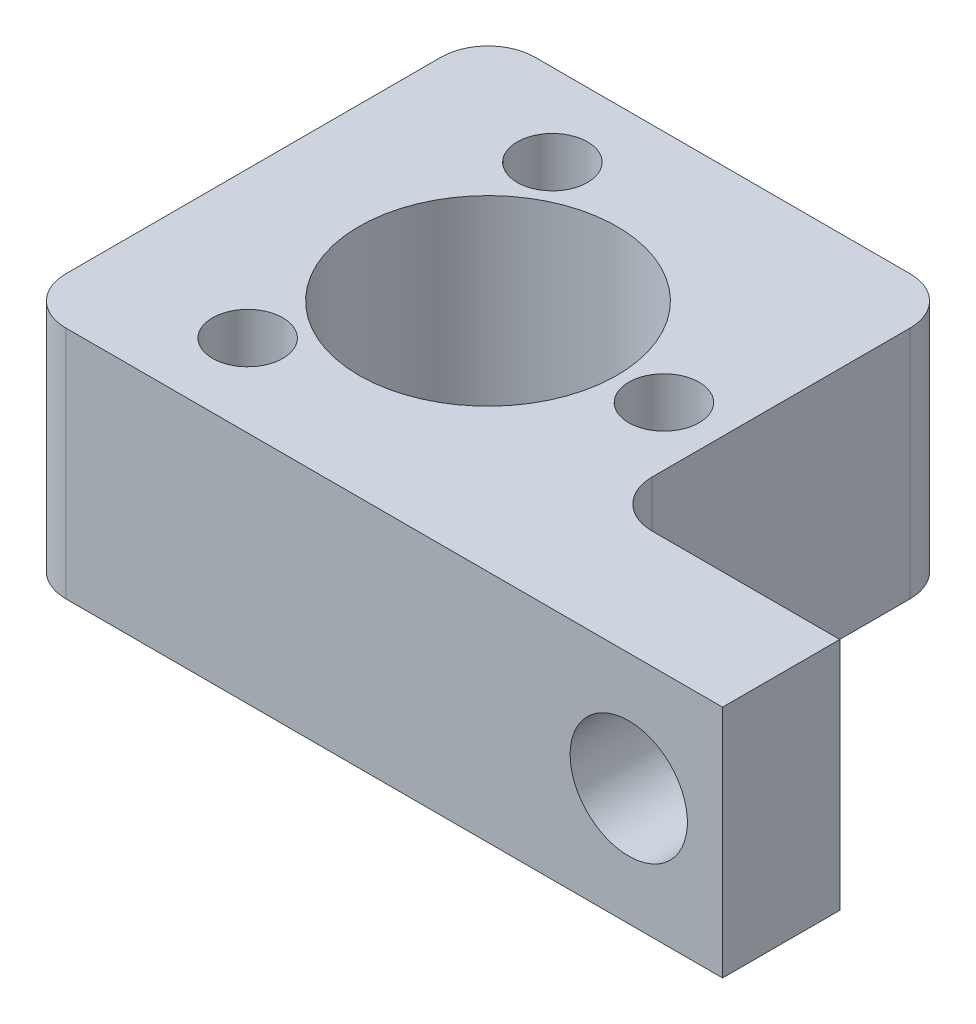
from build123d import *

# Parameters (mm, degrees)
SKETCH1_R           = 1.905
SKETCH1_R_2         = 6.985
BOSS_EXTRUDE1_DEPTH = 12.7
FILLET1_R           = 2.54
SKETCH2_R           = 3.175
CUT_EXTRUDE1_DEPTH  = 7.35


with BuildPart() as part:
    # Sketch1 → Boss-Extrude1 (new body)
    with BuildSketch(Plane(origin=(0, 0, 0), x_dir=(1, 0, 0), z_dir=(0, 1, 0))):
        Polygon((-25.4, 0), (12.7, 0), (12.7, 6.35), (0, 6.35), (0, 25.4), (-25.4, 25.4), align=None)
        with Locations((-17.4625, 4.451108029)):
            Circle(SKETCH1_R, mode=Mode.SUBTRACT)
        with Locations((-3.175, 12.7)):
            Circle(SKETCH1_R, mode=Mode.SUBTRACT)
        with Locations((-12.7, 12.7)):
            Circle(SKETCH1_R_2, mode=Mode.SUBTRACT)
        with Locations((-17.4625, 20.948891971)):
            Circle(SKETCH1_R, mode=Mode.SUBTRACT)
    extrude(amount=BOSS_EXTRUDE1_DEPTH)

    # Fillet1
    fillet1_edges = [part.edges().sort_by_distance(p)[0] for p in [
        (0, 6.35, -6.35),
        (0, 6.35, -25.4),
        (-25.4, 6.35, -25.4),
        (-25.4, 6.35, 0),
    ]]
    fillet(fillet1_edges, radius=FILLET1_R)

    # Sketch2 → Cut-Extrude1 (cut, through all)
    with BuildSketch(Plane(origin=(0, 0, -6.35), x_dir=(-1, 0, 0), z_dir=(0, 0, -1))):
        with Locations((-7.62, 6.35)):
            Circle(SKETCH2_R)
    extrude(amount=-CUT_EXTRUDE1_DEPTH, mode=Mode.SUBTRACT)


solid = part.part
